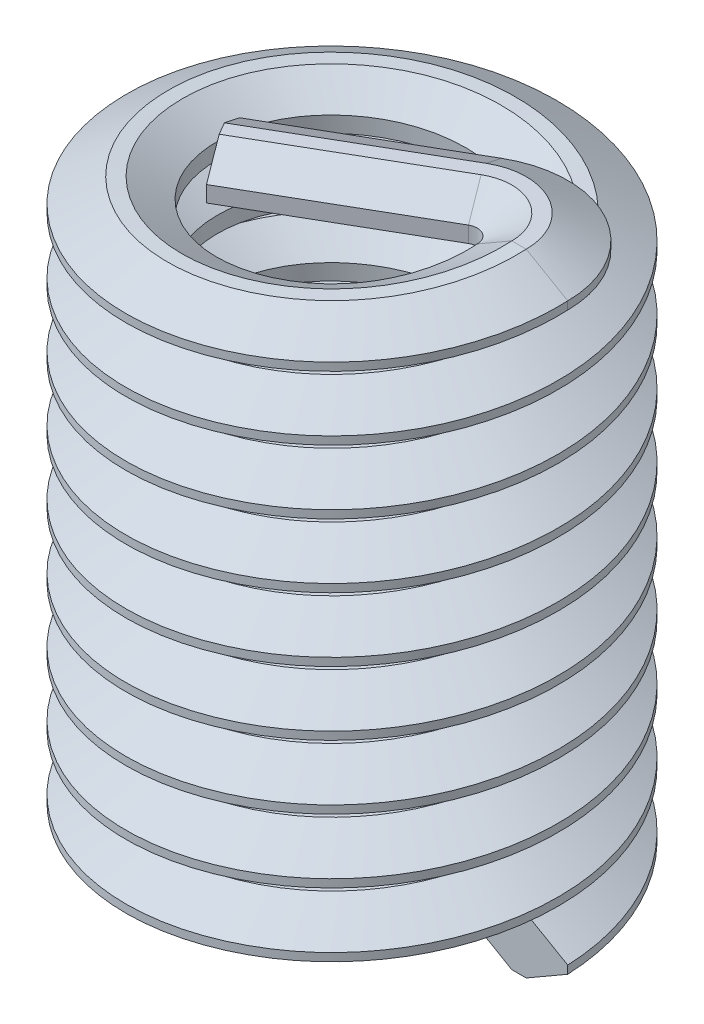
from build123d import *

# Parameters (mm, degrees)
SWEEP1_PITCH       = 0.4
SWEEP1_HEIGHT      = 3.6
SWEEP1_RADIUS      = 1
SWEEP1_START_ANGLE = 90
REVOLVE1_ANGLE     = 120
EXTRUDE1_DEPTH     = 1.2


with BuildPart() as part:
    # Sweep1: sweep along a helix
    with BuildLine() as sweep1_path:
        add(Helix(SWEEP1_PITCH, SWEEP1_HEIGHT, SWEEP1_RADIUS, center=(0, 0, 0), direction=(0, 1, 0), mode=Mode.PRIVATE).rotate(Axis((0, 0, 0), (0, 1, 0)), SWEEP1_START_ANGLE))
    # Sketch1 → Sweep1 (sweep)
    with BuildSketch(Plane(origin=(0, 0, 0), x_dir=(-1, 0, 0), z_dir=(0, 0, 1))):
        Polygon((-1.35, -0.025), (-1.090192379, -0.175), (-1, -0.175), (-0.783493649, -0.05), (-0.783493649, 0.05), (-1, 0.175), (-1.090192379, 0.175), (-1.35, 0.025), align=None)
    sweep(path=sweep1_path.line, is_frenet=True)


with BuildPart() as body_2:
    # Sketch3 → Revolve1 (revolve)
    with BuildSketch(Plane(origin=(0, 0, 0), x_dir=(-1, 0, 0), z_dir=(0, 0, -1))):
        Polygon((-1, 3.425), (-0.783493649, 3.55), (-0.783493649, 3.65), (-1, 3.775), (-1.090192379, 3.775), (-1.35, 3.625), (-1.35, 3.575), (-1.090192379, 3.425), align=None)
    revolve(axis=Axis((0.696891109, 3.6, 0), (0, 1, 0)), revolution_arc=REVOLVE1_ANGLE)

    # Sketch4 → Extrude1 (add)
    with BuildSketch(Plane(origin=(0.522668332, 0, -0.301762702), x_dir=(0.5, -1e-09, 0.866025404), z_dir=(-0.866025404, 0, 0.5))):
        with BuildLine():
            Line((-0.04485572, 3.425), (0.045336658, 3.425))
            Line((0.045336658, 3.425), (0.261843009, 3.55))
            Line((0.261843009, 3.55), (0.261843009, 3.65))
            Line((0.261843009, 3.65), (0.045336658, 3.775))
            add(Edge.make_bspline(
                [(0.045336658, 3.775), (-0.044855721, 3.775)],
                knots=[0, 0, 1, 1], degree=1))
            Line((-0.044855721, 3.775), (-0.304663342, 3.625))
            Line((-0.304663342, 3.625), (-0.304663342, 3.575))
            Line((-0.304663342, 3.575), (-0.04485572, 3.425))
        make_face()
    extrude(amount=EXTRUDE1_DEPTH)


solid = Compound([part.part, body_2.part])
